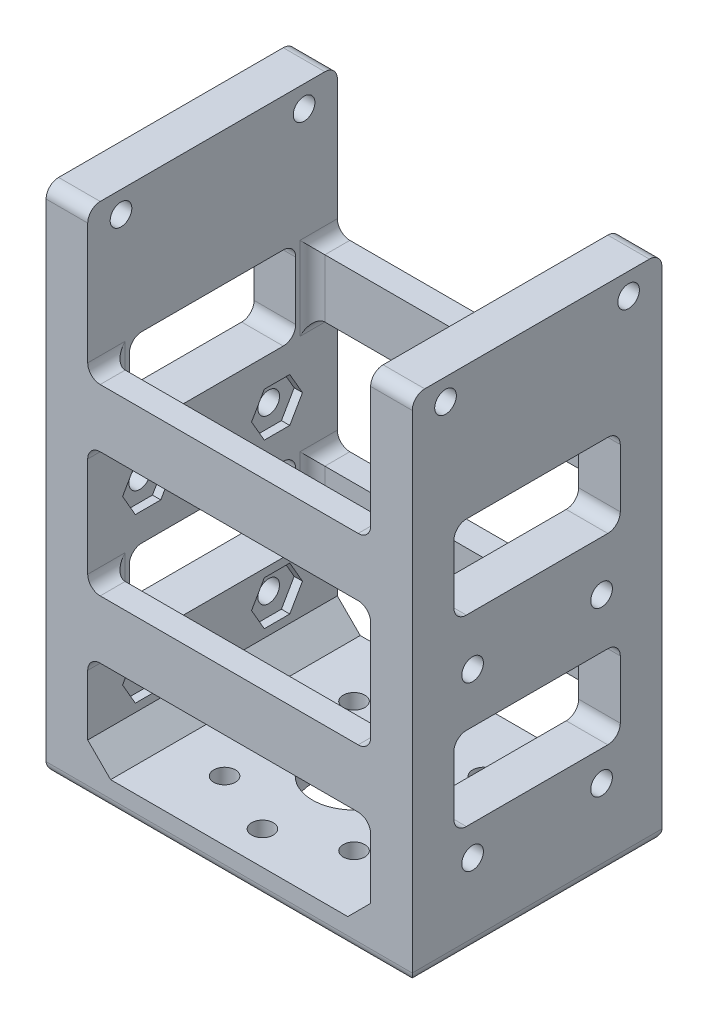
from build123d import *

# Parameters (mm, degrees)
SKETCH1_W            = 44
SKETCH1_H            = 30
BOSS_EXTRUDE1_DEPTH  = 54.5
SKETCH5_W            = 5
SKETCH5_H            = 30
BOSS_EXTRUDE3_DEPTH  = 6.8
SKETCH9_R            = 1.3
CUT_EXTRUDE6_DEPTH   = 79.604643629
FILLET1_R            = 1.5
FILLET2_R            = 1.25
SKETCH11_W           = 34
SKETCH11_H           = 24
CUT_EXTRUDE7_DEPTH   = 51.25
SKETCH13_R           = 5
SKETCH13_R_2         = 1.3
CUT_EXTRUDE8_DEPTH   = 3.5
CIRPATTERN1_COUNT    = 8
CUT_EXTRUDE10_REACH  = 83.202
SKETCH15_W           = 20
SKETCH15_H           = 10
FILLET6_R            = 1.5
FILLET6_OF_MIRROR4_R = 1.5
CUT_EXTRUDE11_REACH  = 83.202
SKETCH16_W           = 34
SKETCH16_H           = 11.5
SKETCH16_H_2         = 10.75
SKETCH16_H_3         = 15
CHAMFER1_SIZE        = 2.75
SKETCH18_R           = 1.3
CUT_EXTRUDE12_DEPTH  = 5
FILLET7_R            = 1.5
CUT_EXTRUDE13_DEPTH  = 1


with BuildPart() as part:
    # Sketch1 → Boss-Extrude1 (new body)
    with BuildSketch(Plane(origin=(0, 0, 0), x_dir=(1, 0, 0), z_dir=(0, 1, 0))):
        with Locations((22, 15)):
            Rectangle(SKETCH1_W, SKETCH1_H)
    extrude(amount=BOSS_EXTRUDE1_DEPTH)

    # Sketch5 → Boss-Extrude3 (add)
    with BuildSketch(Plane(origin=(0, 54.5, 0), x_dir=(1, 0, 0), z_dir=(0, 1, 0))):
        with Locations((2.5, 15)):
            Rectangle(SKETCH5_W, SKETCH5_H)
    boss_extrude3 = extrude(amount=BOSS_EXTRUDE3_DEPTH)

    # Sketch9 → Cut-Extrude6 (cut, through all)
    with BuildSketch(Plane(origin=(5, 0, 0), x_dir=(0, 0, -1), z_dir=(1, 0, 0))):
        with Locations((26, 58.7)):
            Circle(SKETCH9_R)
        with Locations((4, 58.7)):
            Circle(SKETCH9_R)
    cut_extrude6 = extrude(amount=-CUT_EXTRUDE6_DEPTH, mode=Mode.SUBTRACT)

    # Mirror2: Boss-Extrude3, Cut-Extrude6 across plane
    add(boss_extrude3.mirror(Plane.ZY.offset(-22)))
    add(cut_extrude6.mirror(Plane.ZY.offset(-22)), mode=Mode.SUBTRACT)

    # Fillet1
    fillet1_edges = [part.edges().sort_by_distance(p)[0] for p in [
        (41.5, 61.3, -30),
        (2.5, 61.3, -30),
        (2.5, 61.3, 0),
        (41.5, 61.3, 0),
    ]]
    fillet(fillet1_edges, radius=FILLET1_R)

    # Fillet2
    fillet2_edges = [part.edges().sort_by_distance(p)[0] for p in [
        (0, 0, -15),
        (22, 0, -30),
        (22, 0, 0),
        (44, 0, -15),
    ]]
    fillet(fillet2_edges, radius=FILLET2_R)

    # Sketch11 → Cut-Extrude7 (cut)
    with BuildSketch(Plane(origin=(0, 54.5, 0), x_dir=(1, 0, 0), z_dir=(0, 1, 0))):
        with Locations((22, 15)):
            Rectangle(SKETCH11_W, SKETCH11_H)
    extrude(amount=-CUT_EXTRUDE7_DEPTH, mode=Mode.SUBTRACT)

    # Sketch13 → Cut-Extrude8 (cut)
    with BuildSketch(Plane.XZ):
        with Locations((22, -15)):
            Circle(SKETCH13_R)
        with Locations((33, -15)):
            Circle(SKETCH13_R_2)
    cut_extrude8 = extrude(amount=-CUT_EXTRUDE8_DEPTH, mode=Mode.SUBTRACT)

    # CirPattern1: Cut-Extrude8 ×8 about axis
    cirpattern1_axis = Axis((22, 0, -15), (0, -1, 0))
    for i in range(1, CIRPATTERN1_COUNT):
        add(cut_extrude8.rotate(cirpattern1_axis, i * 360 / CIRPATTERN1_COUNT), mode=Mode.SUBTRACT)

    # Sketch15 → Cut-Extrude10 (cut, up to next)
    with BuildSketch(Plane(origin=(44, 0, 0), x_dir=(0, 0, -1), z_dir=(1, 0, 0)), mode=Mode.PRIVATE) as cut_extrude10_sk1:
        with Locations((15, 18.25)):
            Rectangle(SKETCH15_W, SKETCH15_H)
    cut_extrude10_tool1 = extrude(cut_extrude10_sk1.sketch, amount=-CUT_EXTRUDE10_REACH, mode=Mode.PRIVATE) & part.part
    # Sketch15 → Cut-Extrude10 (cut, up to next)
    with BuildSketch(Plane(origin=(44, 0, 0), x_dir=(0, 0, -1), z_dir=(1, 0, 0)), mode=Mode.PRIVATE) as cut_extrude10_sk2:
        with Locations((15, 40.25)):
            Rectangle(SKETCH15_W, SKETCH15_H)
    cut_extrude10_tool2 = extrude(cut_extrude10_sk2.sketch, amount=-CUT_EXTRUDE10_REACH, mode=Mode.PRIVATE) & part.part
    cut_extrude10_1 = cut_extrude10_tool1.solids().sort_by_distance((44, 18.25, -15))[0]
    add(cut_extrude10_1, mode=Mode.SUBTRACT)
    cut_extrude10_2 = cut_extrude10_tool2.solids().sort_by_distance((44, 40.25, -15))[0]
    add(cut_extrude10_2, mode=Mode.SUBTRACT)
    cut_extrude10 = cut_extrude10_1 + cut_extrude10_2  # Cut-Extrude10 as one shape, for the pattern or mirror that repeats it

    # Fillet6
    fillet6_edges = [part.edges().sort_by_distance(p)[0] for p in [
        (41.5, 13.25, -5),
        (41.5, 35.25, -5),
        (41.5, 23.25, -5),
        (41.5, 45.25, -5),
        (41.5, 23.25, -25),
        (41.5, 45.25, -25),
        (41.5, 35.25, -25),
        (41.5, 13.25, -25),
    ]]
    fillet(fillet6_edges, radius=FILLET6_R)

    # Mirror4: Cut-Extrude10 across plane
    add(cut_extrude10.mirror(Plane.ZY.offset(-22)), mode=Mode.SUBTRACT)

    # Fillet6 of Mirror4
    fillet6_of_mirror4_edges = [part.edges().sort_by_distance(p)[0] for p in [
        (2.5, 13.25, -5),
        (2.5, 35.25, -5),
        (2.5, 23.25, -5),
        (2.5, 45.25, -5),
        (2.5, 23.25, -25),
        (2.5, 45.25, -25),
        (2.5, 35.25, -25),
        (2.5, 13.25, -25),
    ]]
    fillet(fillet6_of_mirror4_edges, radius=FILLET6_OF_MIRROR4_R)

    # Sketch16 → Cut-Extrude11 (cut, up to next)
    with BuildSketch(Plane.XY, mode=Mode.PRIVATE) as cut_extrude11_sk1:
        with Locations((22, 9)):
            Rectangle(SKETCH16_W, SKETCH16_H)
    cut_extrude11_tool1 = extrude(cut_extrude11_sk1.sketch, amount=-CUT_EXTRUDE11_REACH, mode=Mode.PRIVATE) & part.part
    # Sketch16 → Cut-Extrude11 (cut, up to next)
    with BuildSketch(Plane.XY, mode=Mode.PRIVATE) as cut_extrude11_sk2:
        with Locations((22, 49.125)):
            Rectangle(SKETCH16_W, SKETCH16_H_2)
    cut_extrude11_tool2 = extrude(cut_extrude11_sk2.sketch, amount=-CUT_EXTRUDE11_REACH, mode=Mode.PRIVATE) & part.part
    # Sketch16 → Cut-Extrude11 (cut, up to next)
    with BuildSketch(Plane.XY, mode=Mode.PRIVATE) as cut_extrude11_sk3:
        with Locations((22, 29.25)):
            Rectangle(SKETCH16_W, SKETCH16_H_3)
    cut_extrude11_tool3 = extrude(cut_extrude11_sk3.sketch, amount=-CUT_EXTRUDE11_REACH, mode=Mode.PRIVATE) & part.part
    cut_extrude11_1 = cut_extrude11_tool1.solids().sort_by_distance((22, 9, 0))[0]
    add(cut_extrude11_1, mode=Mode.SUBTRACT)
    cut_extrude11_2 = cut_extrude11_tool2.solids().sort_by_distance((22, 49.125, 0))[0]
    add(cut_extrude11_2, mode=Mode.SUBTRACT)
    cut_extrude11_3 = cut_extrude11_tool3.solids().sort_by_distance((22, 29.25, 0))[0]
    add(cut_extrude11_3, mode=Mode.SUBTRACT)
    cut_extrude11 = cut_extrude11_1 + cut_extrude11_2 + cut_extrude11_3  # Cut-Extrude11 as one shape, for the pattern or mirror that repeats it

    # Mirror5: Cut-Extrude11 across plane
    add(cut_extrude11.mirror(Plane(origin=(0, 0, -15), x_dir=(1, 0, 0), z_dir=(0, 0, -1))), mode=Mode.SUBTRACT)

    # Chamfer1
    chamfer1_edges = [part.edges().sort_by_distance(p)[0] for p in [
        (5, 3.25, -15),
        (39, 3.25, -15),
    ]]
    chamfer(chamfer1_edges, length=CHAMFER1_SIZE)

    # Sketch18 → Cut-Extrude12 (cut)
    with BuildSketch(Plane.ZY):
        with Locations((-22.75, 29.25)):
            Circle(SKETCH18_R)
        with Locations((-7.25, 29.25)):
            Circle(SKETCH18_R)
        with Locations((-22.75, 9.625)):
            Circle(SKETCH18_R)
        with Locations((-7.25, 9.625)):
            Circle(SKETCH18_R)
    cut_extrude12 = extrude(amount=-CUT_EXTRUDE12_DEPTH, mode=Mode.SUBTRACT)

    # Fillet7
    fillet7_edges = [part.edges().sort_by_distance(p)[0] for p in [
        (39, 36.75, -28.5),
        (39, 36.75, -1.5),
        (39, 14.75, -1.5),
        (39, 14.75, -28.5),
        (5, 14.75, -1.5),
        (5, 36.75, -1.5),
        (5, 36.75, -28.5),
        (5, 14.75, -28.5),
        (5, 18.25, -3),
        (39, 18.25, -3),
        (39, 40.25, -3),
        (5, 40.25, -3),
        (5, 18.25, -27),
        (5, 40.25, -27),
        (39, 40.25, -27),
        (39, 18.25, -27),
        (39, 21.75, -28.5),
        (5, 21.75, -1.5),
        (5, 21.75, -28.5),
        (39, 21.75, -1.5),
        (39, 43.75, -1.5),
        (39, 43.75, -28.5),
        (5, 43.75, -28.5),
        (5, 43.75, -1.5),
    ]]
    fillet(fillet7_edges, radius=FILLET7_R)

    # Sketch19 → Cut-Extrude13 (cut)
    with BuildSketch(Plane(origin=(5, 0, 0), x_dir=(0, 0, -1), z_dir=(1, 0, 0))):
        Polygon((8.779978213, 26.6), (10.309956427, 29.25), (8.779978213, 31.9), (5.720021787, 31.9), (4.190043573, 29.25), (5.720021787, 26.6), align=None)
        Polygon((21.220021787, 26.6), (24.279978213, 26.6), (25.809956427, 29.25), (24.279978213, 31.9), (21.220021787, 31.9), (19.690043573, 29.25), align=None)
        Polygon((5.720021787, 6.975), (8.779978213, 6.975), (10.309956427, 9.625), (8.779978213, 12.275), (5.720021787, 12.275), (4.190043573, 9.625), align=None)
        Polygon((21.220021787, 6.975), (24.279978213, 6.975), (25.809956427, 9.625), (24.279978213, 12.275), (21.220021787, 12.275), (19.690043573, 9.625), align=None)
    cut_extrude13 = extrude(amount=-CUT_EXTRUDE13_DEPTH, mode=Mode.SUBTRACT)

    # Mirror6: Cut-Extrude12, Cut-Extrude13 across plane
    add(cut_extrude12.mirror(Plane.ZY.offset(-22)), mode=Mode.SUBTRACT)
    add(cut_extrude13.mirror(Plane.ZY.offset(-22)), mode=Mode.SUBTRACT)


solid = part.part
